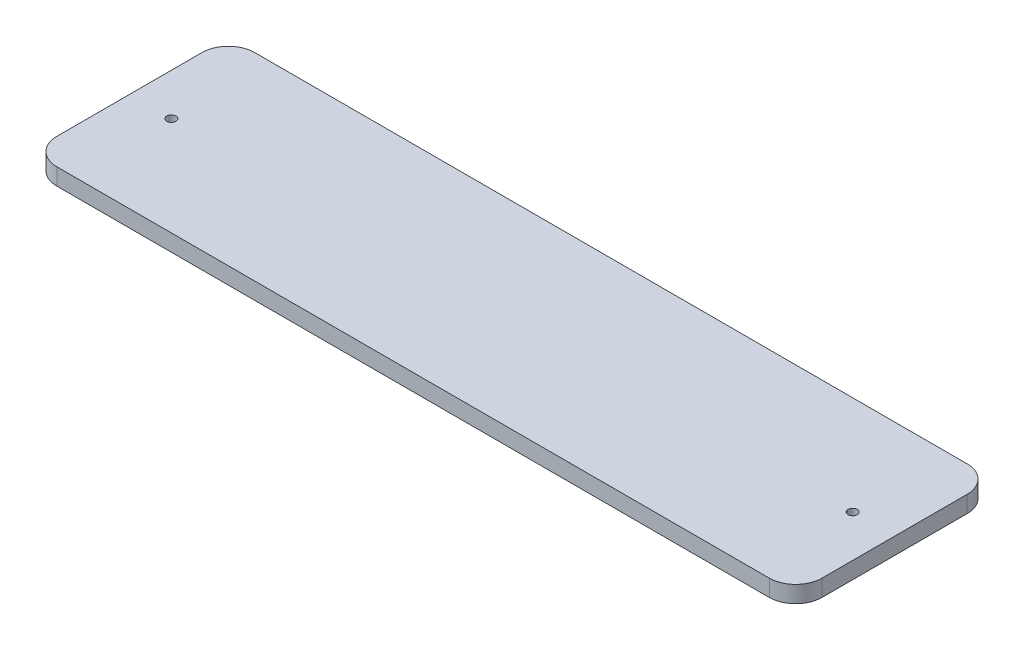
from build123d import *

# Parameters (mm, degrees)
SKETCH1_W           = 290
SKETCH1_H           = 75
BOSS_EXTRUDE1_DEPTH = 6.35
SKETCH2_R           = 1.75
CUT_EXTRUDE1_DEPTH  = 7.35
SKETCH3_R           = 1.75
CUT_EXTRUDE2_DEPTH  = 7.35
FILLET1_R           = 10


with BuildPart() as part:
    # Sketch1 → Boss-Extrude1 (new body)
    with BuildSketch(Plane(origin=(0, 0, 0), x_dir=(1, 0, 0), z_dir=(0, 1, 0))):
        Rectangle(SKETCH1_W, SKETCH1_H)
    extrude(amount=BOSS_EXTRUDE1_DEPTH)

    # Sketch2 → Cut-Extrude1 (cut, through all)
    with BuildSketch(Plane(origin=(0, 6.35, 0), x_dir=(1, 0, 0), z_dir=(0, 1, 0))):
        with Locations((-129.12, 0)):
            Circle(SKETCH2_R)
    extrude(amount=-CUT_EXTRUDE1_DEPTH, mode=Mode.SUBTRACT)

    # Sketch3 → Cut-Extrude2 (cut, through all)
    with BuildSketch(Plane(origin=(0, 6.35, 0), x_dir=(1, 0, 0), z_dir=(0, 1, 0))):
        with Locations((129.12, 0)):
            Circle(SKETCH3_R)
    extrude(amount=-CUT_EXTRUDE2_DEPTH, mode=Mode.SUBTRACT)

    # Fillet1
    fillet1_edges = [part.edges().sort_by_distance(p)[0] for p in [
        (145, 3.175, 37.5),
        (-145, 3.175, 37.5),
        (-145, 3.175, -37.5),
        (145, 3.175, -37.5),
    ]]
    fillet(fillet1_edges, radius=FILLET1_R)


solid = part.part
